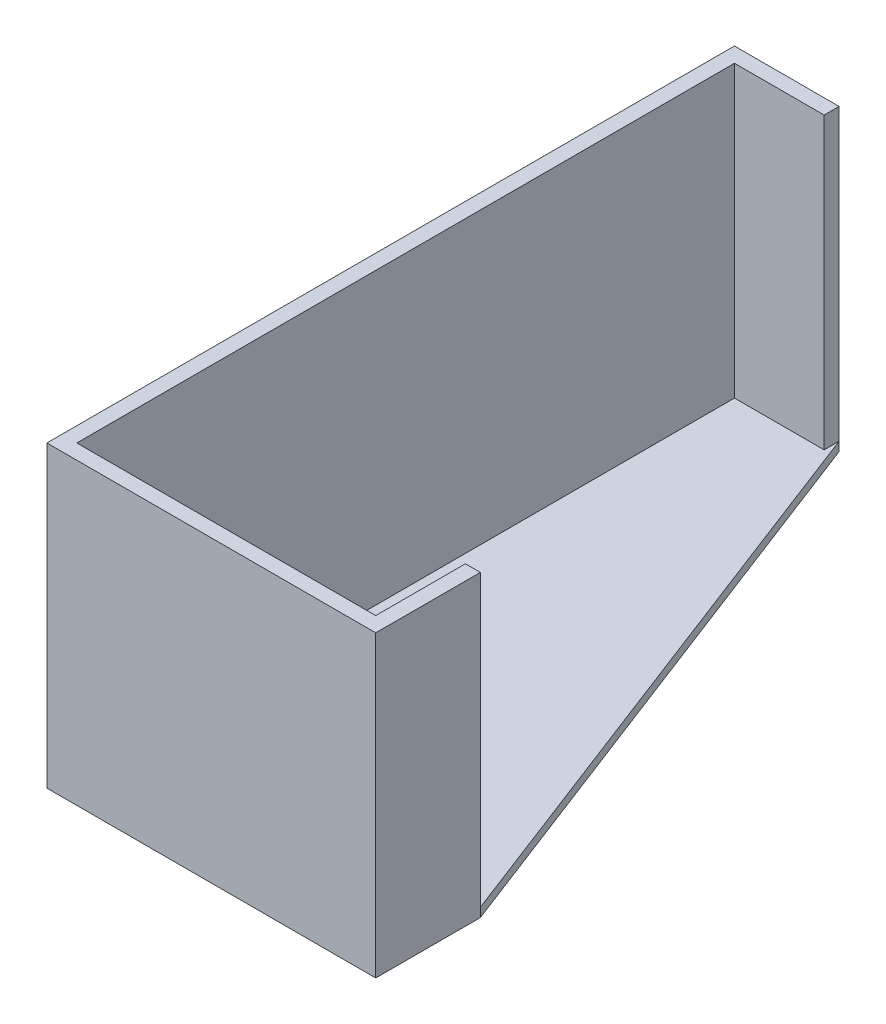
from build123d import *

# Parameters (mm, degrees)
ESTRUSIONE_ESTRUSIONE1_DEPTH = 100
ESTRUSIONE_ESTRUSIONE2_DEPTH = 3


with BuildPart() as part:
    # Schizzo1 → Estrusione-Estrusione1 (new body)
    with BuildSketch(Plane(origin=(0, 0, 0), x_dir=(1, 0, 0), z_dir=(0, 1, 0))):
        Polygon((100, 0), (0, 0), (0, 220), (30, 220), (30, 225), (-5, 225), (-5, -5), (105, -5), (105, 30), (100, 30), align=None)
    extrude(amount=ESTRUSIONE_ESTRUSIONE1_DEPTH)

    # Schizzo2 → Estrusione-Estrusione2 (add)
    with BuildSketch(Plane.XZ):
        Polygon((30, -225), (-5, -225), (-5, 5), (105, 5), (105, -30), align=None)
    extrude(amount=-ESTRUSIONE_ESTRUSIONE2_DEPTH)


solid = part.part
